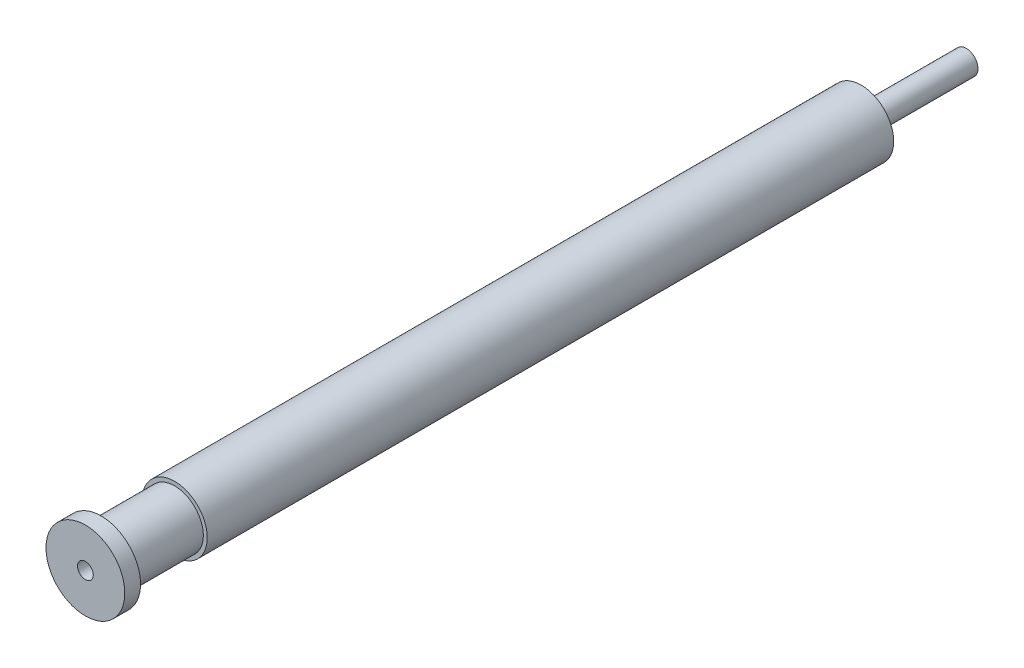
from build123d import *

# Parameters (mm, degrees)
SKETCH3_R          = 0.75
CUT_EXTRUDE6_DEPTH = 84.84194368


with BuildPart() as part:
    # Sketch2 → Revolve4 (revolve)
    with BuildSketch(Plane(origin=(0, 0, 0), x_dir=(1, 0, 0), z_dir=(0, 1, 0))):
        Polygon((24.868249983, 17.00561082), (24.868249983, -55.99438918), (28.618249983, -55.99438918), (28.618249983, -54.49438918), (27.593249983, -54.49438918), (27.593249983, -47.49438918), (27.968249983, -47.49438918), (27.968249983, 17.8475545), (25.993249983, 17.8475545), (25.993249983, 27.8475545), (24.868249983, 27.8475545), align=None)
    revolve(axis=Axis((24.868249983, 0, -17.00561082), (0, 0, 1)))

    # Sketch3 → Cut-Extrude6 (cut, through all)
    with BuildSketch(Plane.XY.offset(55.99438918)):
        with Locations((24.868249983, 0)):
            Circle(SKETCH3_R)
    extrude(amount=-CUT_EXTRUDE6_DEPTH, mode=Mode.SUBTRACT)


solid = part.part
